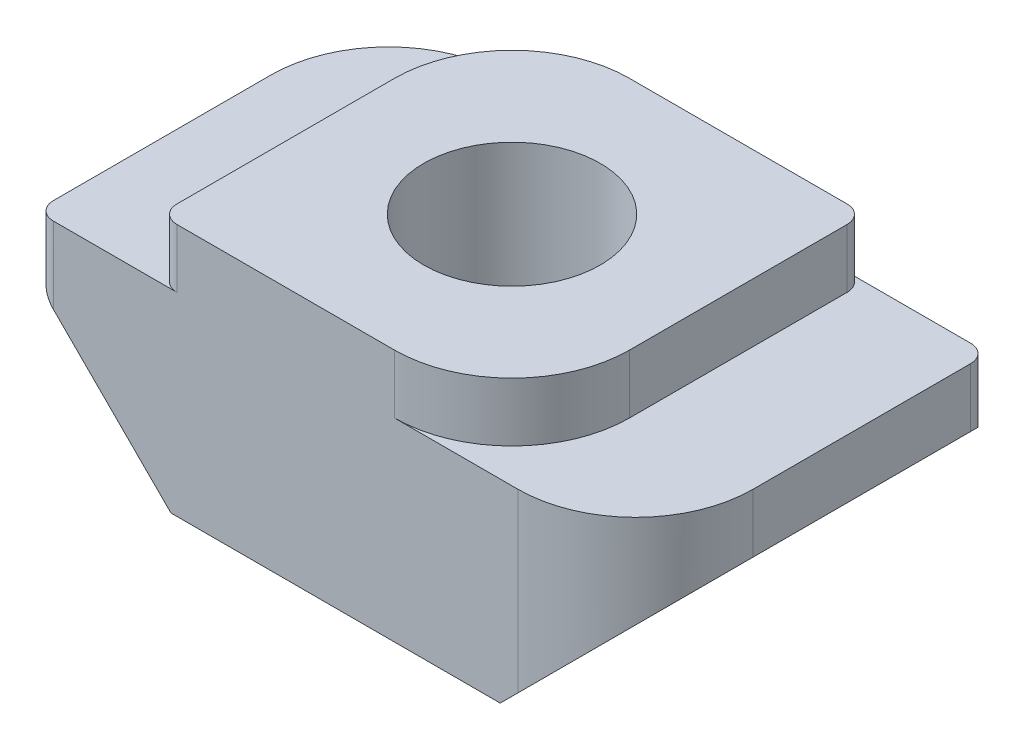
from build123d import *

# Parameters (mm, degrees)
EXTRUDE_1_DEPTH     = 6
FILLET_1_R          = 2
FILLET_2_R          = 2
FILLET_3_R          = 0.3
SKETCH_2_R          = 1.5
CUT_EXTRUDE_1_DEPTH = 6


with BuildPart() as part:
    # 草图1 → 凸台-拉伸1 (new body)
    with BuildSketch(Plane.XY):
        Polygon((-3, 4.3), (3, 4.3), (3, 3.3), (5.1, 3.3), (5.1, 2.3), (2.8, 0), (-2.8, 0), (-5.1, 2.3), (-5.1, 3.3), (-3, 3.3), align=None)
    extrude(amount=EXTRUDE_1_DEPTH)

    # 圆角1
    fillet_1_edges = [part.edges().sort_by_distance(p)[0] for p in [
        (-3, 3.8, 0),
        (3, 3.8, 6),
    ]]
    fillet(fillet_1_edges, radius=FILLET_1_R)

    # 圆角2
    fillet_2_edges = [part.edges().sort_by_distance(p)[0] for p in [
        (-5.1, 2.8, 0),
        (5.1, 2.8, 6),
    ]]
    fillet(fillet_2_edges, radius=FILLET_2_R)

    # 圆角3
    fillet_3_edges = [part.edges().sort_by_distance(p)[0] for p in [
        (-3, 3.8, 6),
        (3, 3.8, 0),
        (-5.1, 2.8, 6),
        (5.1, 2.8, 0),
    ]]
    fillet(fillet_3_edges, radius=FILLET_3_R)

    # 草图2 → 切除-拉伸1 (cut)
    with BuildSketch(Plane(origin=(0, 4.3, 0), x_dir=(1, 0, 0), z_dir=(0, 1, 0))):
        with Locations((0, -3)):
            Circle(SKETCH_2_R)
    extrude(amount=-CUT_EXTRUDE_1_DEPTH, mode=Mode.SUBTRACT)


solid = part.part
